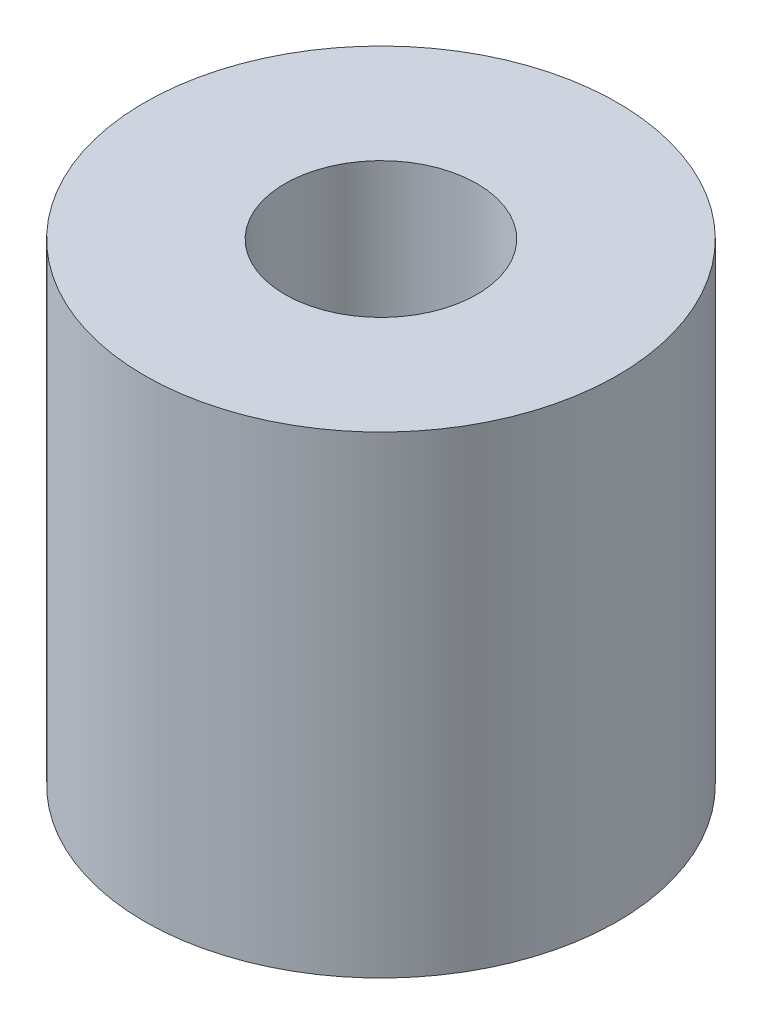
from build123d import *

# Parameters (mm, degrees)
SKETCH1_R           = 4
SKETCH1_R_2         = 1.625
BOSS_EXTRUDE1_DEPTH = 8


with BuildPart() as part:
    # Sketch1 → Boss-Extrude1 (new body)
    with BuildSketch(Plane(origin=(0, 0, 0), x_dir=(1, 0, 0), z_dir=(0, 1, 0))):
        Circle(SKETCH1_R)
        Circle(SKETCH1_R_2, mode=Mode.SUBTRACT)
    extrude(amount=BOSS_EXTRUDE1_DEPTH)


solid = part.part
